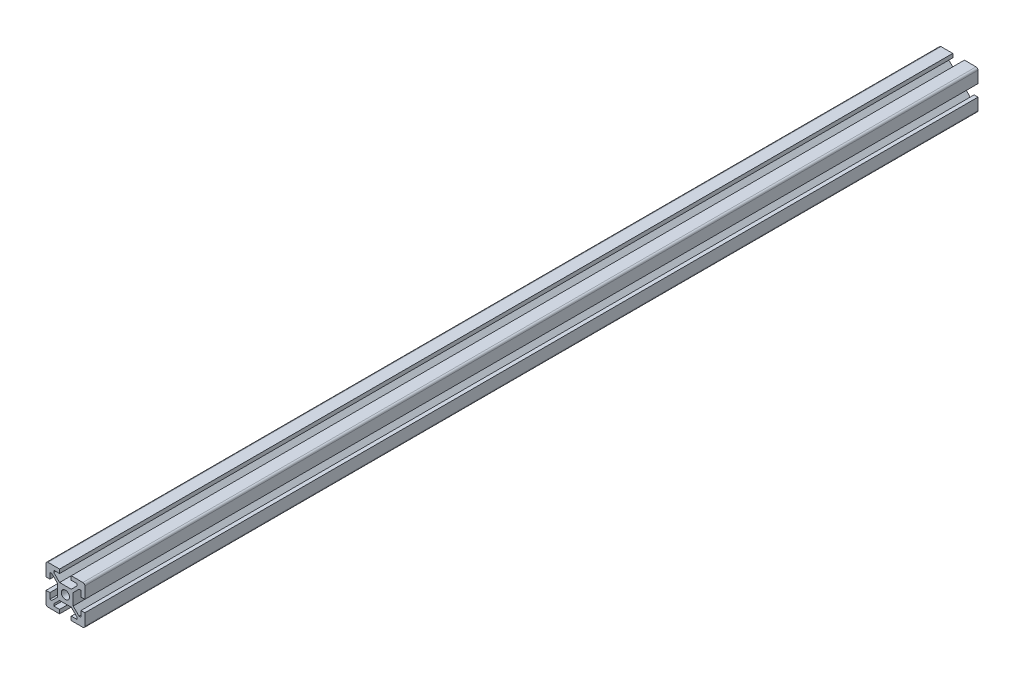
from build123d import *

# Parameters (mm, degrees)
SCHIZZO1_R                   = 2.1
ESTRUSIONE_ESTRUSIONE1_DEPTH = 460
RACCORDO1_R                  = 1


with BuildPart() as part:
    # Schizzo1 → Estrusione-Estrusione1 (new body)
    with BuildSketch(Plane.XY):
        Polygon((10, 3), (10, 10), (3, 10), (3, 8), (6, 8), (6, 7), (3, 4), (-3, 4), (-6, 7), (-6, 8), (-3, 8), (-3, 10), (-10, 10), (-10, 3), (-8, 3), (-8, 6), (-7, 6), (-4, 3), (-4, -3), (-7, -6), (-8, -6), (-8, -3), (-10, -3), (-10, -10), (-3, -10), (-3, -8), (-6, -8), (-6, -7), (-3, -4), (3, -4), (6, -7), (6, -8), (3, -8), (3, -10), (10, -10), (10, -3), (8, -3), (8, -6), (7, -6), (4, -3), (4, 3), (7, 6), (8, 6), (8, 3), align=None)
        Circle(SCHIZZO1_R, mode=Mode.SUBTRACT)
    extrude(amount=ESTRUSIONE_ESTRUSIONE1_DEPTH)

    # Raccordo1
    raccordo1_edges = [part.edges().sort_by_distance(p)[0] for p in [
        (-10, 10, 230),
        (10, 10, 230),
        (10, -10, 230),
        (-10, -10, 230),
    ]]
    fillet(raccordo1_edges, radius=RACCORDO1_R)


solid = part.part
